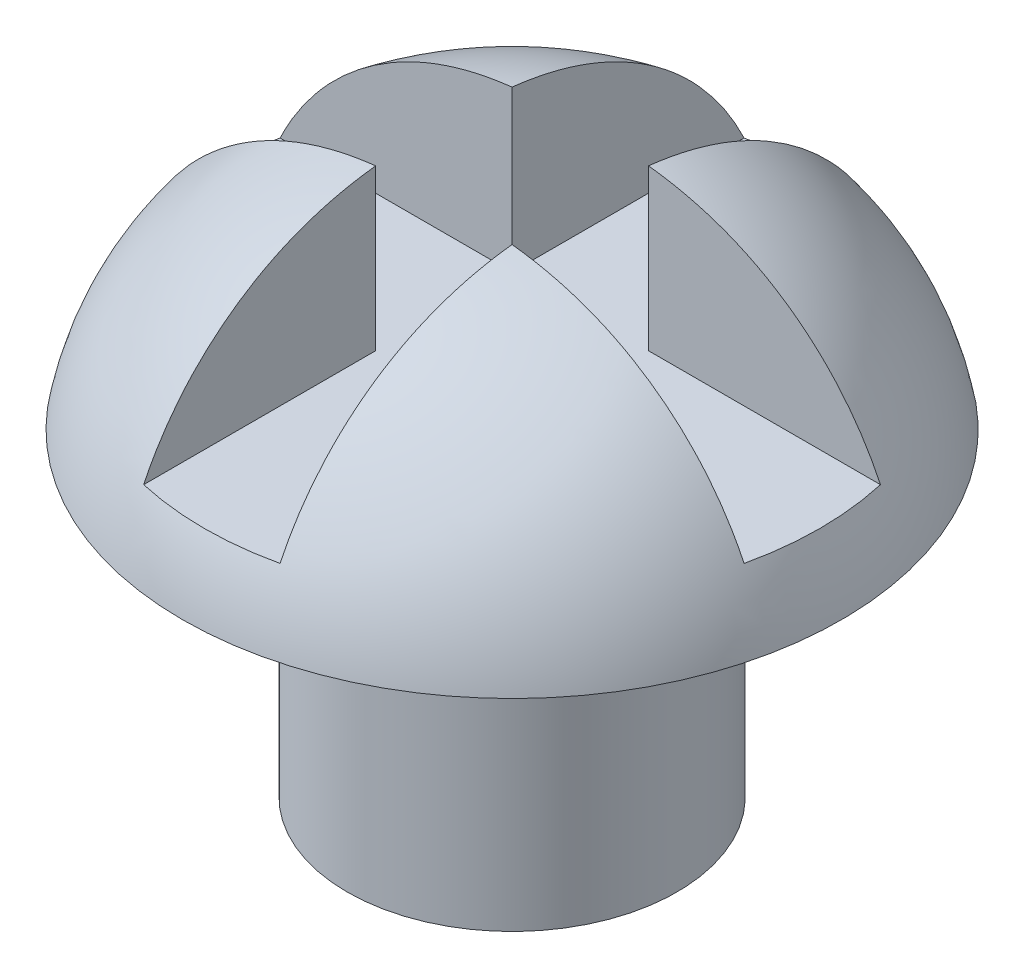
from build123d import *

# Parameters (mm, degrees)
CUT_EXTRUDE1_DEPTH  = 3.048
SKETCH3_R           = 1.842682312
BOSS_EXTRUDE1_DEPTH = 3.556


with BuildPart() as part:
    # Sketch1 → Revolve1 (revolve)
    with BuildSketch(Plane.XY):
        with BuildLine():
            Line((0, 0), (3.683, 0))
            ThreePointArc((3.683, 0), (2.367551224, 2.032774275), (0, 2.54))
            Line((0, 2.54), (0, 0))
        make_face()
    revolve(axis=Axis((0, 23.833116883, 0), (0, -1, 0)))

    # Sketch2 → Cut-Extrude1 (cut)
    with BuildSketch(Plane(origin=(0, 3.81, 0), x_dir=(-1, 0, 0), z_dir=(0, -1, 0))):
        Polygon((-0.762, -0.762), (-0.762, -3.958262237), (0.762, -3.958262237), (0.762, -0.762), (5.504133478, -0.762), (5.504133478, 0.762), (0.762, 0.762), (0.762, 3.972126553), (-0.762, 3.972126553), (-0.762, 0.762), (-5.060475364, 0.762), (-5.060475364, -0.762), align=None)
    extrude(amount=CUT_EXTRUDE1_DEPTH, mode=Mode.SUBTRACT)

    # Sketch3 → Boss-Extrude1 (add)
    with BuildSketch(Plane.XZ):
        Circle(SKETCH3_R)
    extrude(amount=BOSS_EXTRUDE1_DEPTH)


solid = part.part
